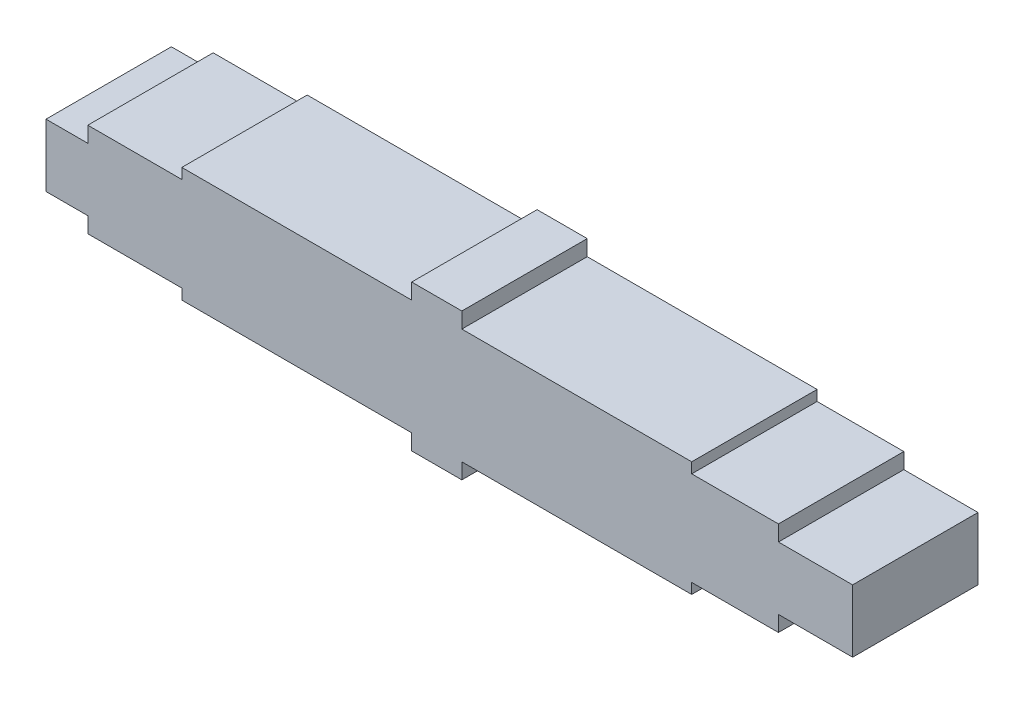
from build123d import *

# Parameters (mm, degrees)
BOSS_EXTRUDE1_DEPTH      = 30
BOSS_EXTRUDE1_DEPTH_BACK = 30


with BuildPart() as part:
    # Sketch1 → Boss-Extrude1 (new, two sides: drawn at the far end of the back side and taken through both)
    with BuildSketch(Plane.XY.offset(-BOSS_EXTRUDE1_DEPTH_BACK)):
        Polygon((-12, -15), (-12, 15), (8, 15), (8, 22.5), (53, 22.5), (53, 27.5), (163, 27.5), (163, 35), (187, 35), (187, 27.5), (297, 27.5), (297, 22.5), (338.5, 22.5), (338.5, 15), (374, 15), (374, -15), (338.5, -15), (338.5, -22.5), (297, -22.5), (297, -27.5), (187, -27.5), (187, -35), (163, -35), (163, -27.5), (53, -27.5), (53, -22.5), (8, -22.5), (8, -15), align=None)
    extrude(amount=BOSS_EXTRUDE1_DEPTH + BOSS_EXTRUDE1_DEPTH_BACK)

    # Sketch3 → Cut-Revolve2 (revolve, cut)
    with BuildSketch(Plane.XY):
        with BuildLine():
            Line((108.000005708, 22.495261034), (108.000005708, 23.617924612))
            add(Edge.make_bspline(
                [(108.000005708, 23.617924612), (108.69532236, 23.632492565), (110.134086752, 23.662696241), (114.002675386, 23.744055355), (117.52452678, 23.818734211), (122.62413086, 23.927066751), (127.386175822, 24.028960617), (133.517001276, 24.160489916), (140.669558615, 24.314757893), (149.244027294, 24.50035769), (158.933260023, 24.710843629), (169.003951816, 24.929828541), (178.945846596, 25.146047878), (189.059333627, 25.365529494), (198.913066308, 25.578918803), (209.188065069, 25.800360703), (218.243647, 25.994865885), (227.18153574, 26.185528835), (233.191375828, 26.313403618), (238.874035778, 26.433622484), (240.957024273, 26.477631494), (241.999996023, 26.499636974)],
                knots=[0.083332146, 0.083332146, 0.083332146, 0.083332146, 0.083332146, 0.104087624, 0.126568088, 0.157701305, 0.188834523, 0.21996774, 0.251100957, 0.30685696, 0.369123394, 0.431389829, 0.493656263, 0.555922697, 0.618189132, 0.680455566, 0.742722, 0.804988435, 0.85440094, 0.885534157, 0.916667375, 0.916667375, 0.916667375, 0.916667375, 0.916667375], degree=4))
            Line((241.999996023, 26.499636974), (241.999996023, 25.386328483))
            add(Edge.make_bspline(
                [(241.999996023, 25.386328483), (242.997689398, 25.308156454), (244.990789981, 25.150456292), (248.314178963, 24.884174364), (251.097793918, 24.652630256), (254.096338207, 24.40199426), (256.115950151, 24.228401113), (258.395425806, 24.031542714), (260.523519631, 23.843523656), (263.272962125, 23.597575487), (267.617740398, 23.199581767), (272.530644228, 22.731603556), (277.969218388, 22.186806055), (284.502123723, 21.495795918), (289.937964032, 20.886548872), (295.372437907, 20.237558818), (301.88455361, 19.401221609), (308.389001931, 18.498768615), (315.959550127, 17.326428718), (324.308730313, 15.802761995), (331.522595168, 14.182607232), (337.270373253, 12.534677442), (341.314142899, 11.019210316), (343.839526129, 9.821610423), (345.557398761, 8.80275637), (346.740922219, 7.936545395), (347.594801698, 7.171388914), (348.227306411, 6.479610121), (348.723002975, 5.813945223), (349.119004405, 5.147021841), (349.440992029, 4.441727447), (349.699673959, 3.650874012), (349.887237793, 2.736043875), (349.971487339, 1.848234223), (349.997159077, 1.02099573), (350.000343601, 0.437547408), (350.000420527, 0.145847197), (350, 0)],
                knots=[0.085539691, 0.085539691, 0.085539691, 0.085539691, 0.085539691, 0.120111184, 0.154682677, 0.171968424, 0.189254171, 0.206539917, 0.223825664, 0.241111411, 0.258397158, 0.292968652, 0.362111638, 0.396683132, 0.431254625, 0.500397611, 0.534969105, 0.5695406, 0.638683586, 0.707826572, 0.776969547, 0.837594824, 0.8721664, 0.896549847, 0.913250965, 0.925776395, 0.935170687, 0.942808737, 0.949414163, 0.955338894, 0.96134561, 0.967265833, 0.973858415, 0.981569814, 0.990784907, 0.995392454, 1, 1, 1, 1, 1], degree=4))
            Line((350, 0), (0, 0))
            add(Edge.make_bspline(
                [(0, 0), (-0.00035577, 0.120277327), (-0.00031082, 0.360836588), (0.002299922, 0.841992826), (0.022856294, 1.520243321), (0.089579031, 2.24292924), (0.236719839, 2.986493577), (0.43616989, 3.622237895), (0.687299533, 4.198977779), (1.002920086, 4.75468844), (1.407889824, 5.319720548), (1.939569813, 5.917175139), (2.658583589, 6.573081931), (3.67793434, 7.327261742), (5.178835477, 8.218030187), (7.500122996, 9.307468959), (11.351007882, 10.703965668), (16.999713662, 12.236154029), (24.236498755, 13.742442968), (32.666050698, 15.149254822), (41.486862914, 16.386268296), (49.223740463, 17.330086994), (55.862579827, 18.066429658), (61.400762894, 18.639952996), (65.830769492, 19.077356076), (70.267988209, 19.496098455), (74.697234615, 19.8971343), (79.144191725, 20.283849996), (83.564092337, 20.654572527), (87.478187448, 20.970893), (90.760753774, 21.229595839), (93.610940803, 21.448494052), (95.697915689, 21.607520734), (98.724377463, 21.832083001), (101.588044864, 22.043264026), (104.94931787, 22.282042977), (106.985221031, 22.424804888), (108.000005708, 22.495261034)],
                knots=[0, 0, 0, 0, 0, 0.003837631, 0.007675261, 0.015350522, 0.021646811, 0.026957895, 0.031813386, 0.036568429, 0.041680559, 0.047310658, 0.053953193, 0.062039099, 0.07267917, 0.087698911, 0.109550262, 0.143736552, 0.203218265, 0.274262491, 0.345306722, 0.416350952, 0.487395185, 0.522917301, 0.558439418, 0.593961534, 0.629483651, 0.665005767, 0.700527884, 0.73605, 0.771572117, 0.789333175, 0.807094233, 0.824855291, 0.842616349, 0.878138465, 0.913660582, 0.913660582, 0.913660582, 0.913660582, 0.913660582], degree=4))
        make_face()
    revolve(axis=Axis((-1000, 0, 0), (1, 0, 0)), mode=Mode.SUBTRACT)


solid = part.part
